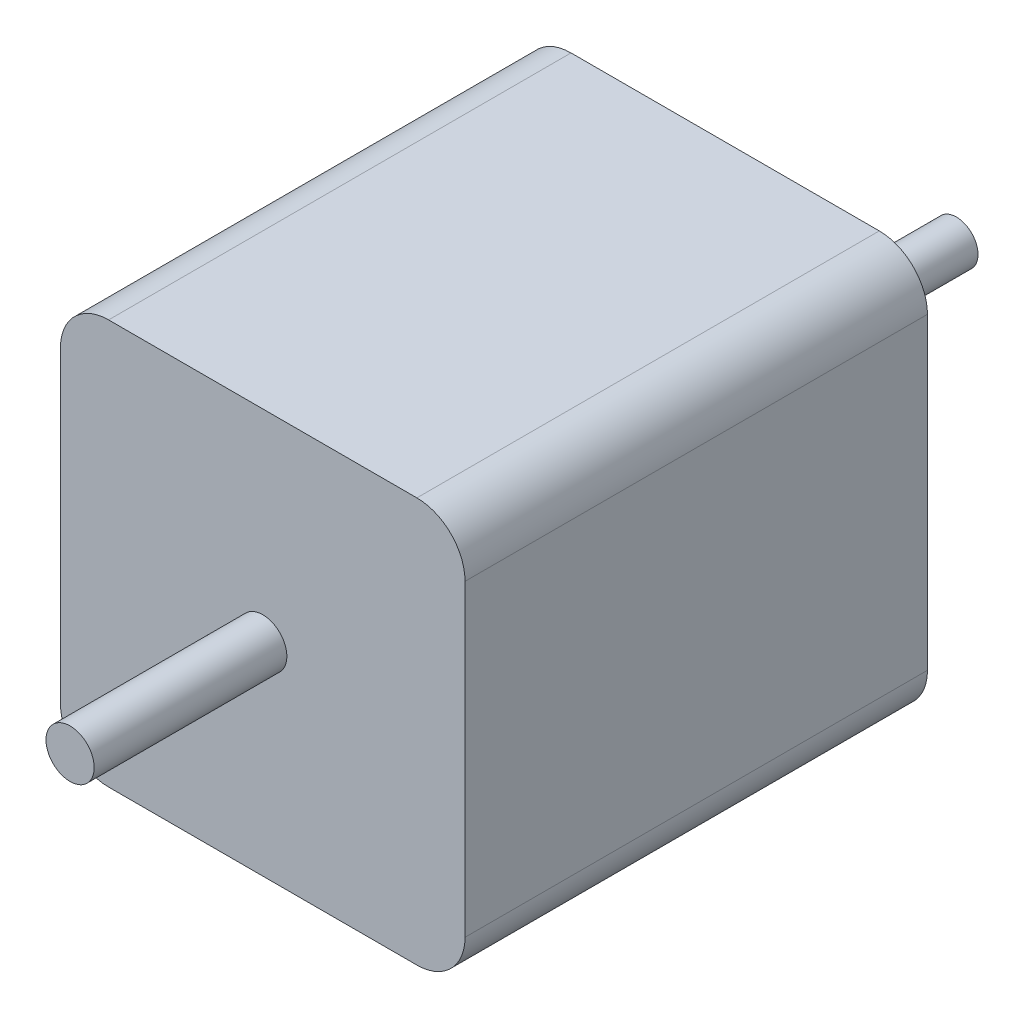
from build123d import *

# Parameters (mm, degrees)
SKETCH_1_W          = 42
SKETCH_1_H          = 42
EXTRUDE_1_DEPTH     = 48
SKETCH_2_R          = 11
EXTRUDE_2_DEPTH     = 2
SKETCH_3_R          = 2.25
EXTRUDE_3_DEPTH     = 22
SKETCH_4_R          = 1.5
CUT_EXTRUDE_1_DEPTH = 4.5
FILLET_1_R          = 5
SKETCH_5_R          = 2.5
EXTRUDE_4_DEPTH     = 20


with BuildPart() as part:
    # 草图1 → 凸台-拉伸1 (new body)
    with BuildSketch(Plane.XY):
        Rectangle(SKETCH_1_W, SKETCH_1_H)
    extrude(amount=EXTRUDE_1_DEPTH)

    # 草图2 → 凸台-拉伸2 (add)
    with BuildSketch(Plane(origin=(0, 0, 0), x_dir=(-1, 0, 0), z_dir=(0, 0, -1))):
        Circle(SKETCH_2_R)
    extrude(amount=EXTRUDE_2_DEPTH)

    # 草图3 → 凸台-拉伸3 (add)
    with BuildSketch(Plane(origin=(0, 0, -2), x_dir=(-1, 0, 0), z_dir=(0, 0, -1))):
        Circle(SKETCH_3_R)
    extrude(amount=EXTRUDE_3_DEPTH)

    # 草图4 → 切除-拉伸1 (cut)
    with BuildSketch(Plane(origin=(0, 0, 0), x_dir=(-1, 0, 0), z_dir=(0, 0, -1))):
        with Locations((-15.5, 15.5)):
            Circle(SKETCH_4_R)
        with Locations((15.5, 15.5)):
            Circle(SKETCH_4_R)
        with Locations((15.5, -15.5)):
            Circle(SKETCH_4_R)
        with Locations((-15.5, -15.5)):
            Circle(SKETCH_4_R)
    extrude(amount=-CUT_EXTRUDE_1_DEPTH, mode=Mode.SUBTRACT)

    # 圆角1
    fillet_1_edges = [part.edges().sort_by_distance(p)[0] for p in [
        (21, -21, 24),
        (-21, -21, 24),
        (-21, 21, 24),
        (21, 21, 24),
    ]]
    fillet(fillet_1_edges, radius=FILLET_1_R)

    # 草图5 → 凸台-拉伸4 (add)
    with BuildSketch(Plane.XY.offset(48)):
        Circle(SKETCH_5_R)
    extrude(amount=EXTRUDE_4_DEPTH)


solid = part.part
